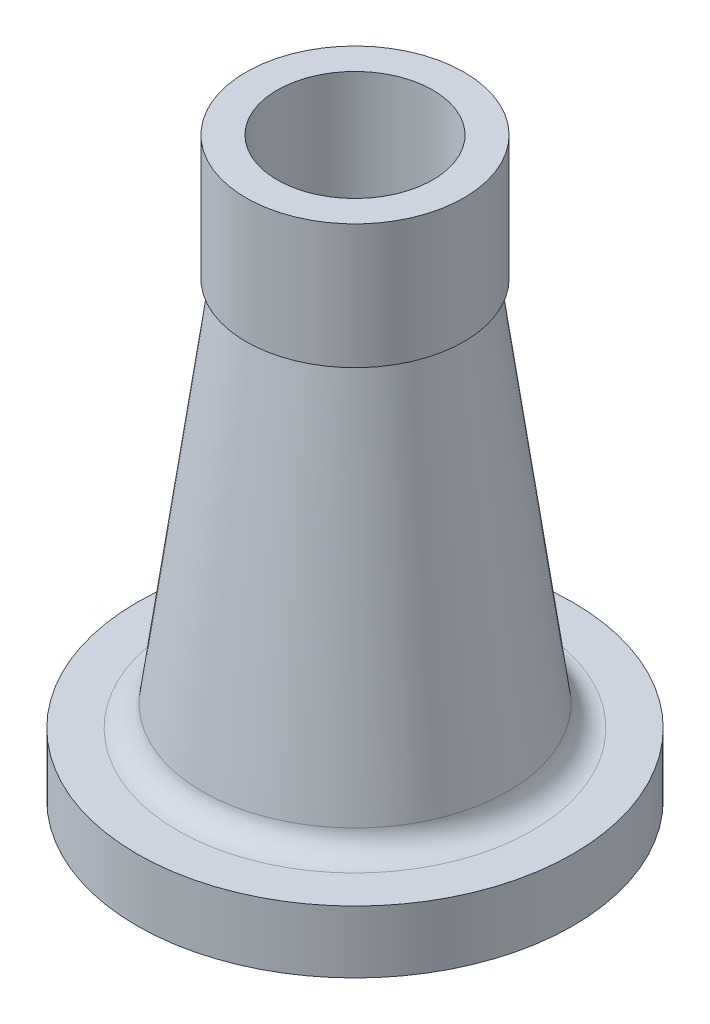
from build123d import *

# Parameters (mm, degrees)
FILLET1_R = 8


with BuildPart() as part:
    # Sketch1 → Revolve1 (revolve)
    with BuildSketch(Plane.XY):
        Polygon((50, 0), (70, 0), (70, 20), (50, 20), (33, 145), (35, 145), (35, 185), (25, 185), (25, 129.61723322), (42.219943718, 3), (50, 3), align=None)
    revolve(axis=Axis((0, 0, 0), (0, 1, 0)))

    # Fillet1
    fillet1_edges = [part.edges().sort_by_distance(p)[0] for p in [
        (-50, 20, 0),
    ]]
    fillet(fillet1_edges, radius=FILLET1_R)


solid = part.part
